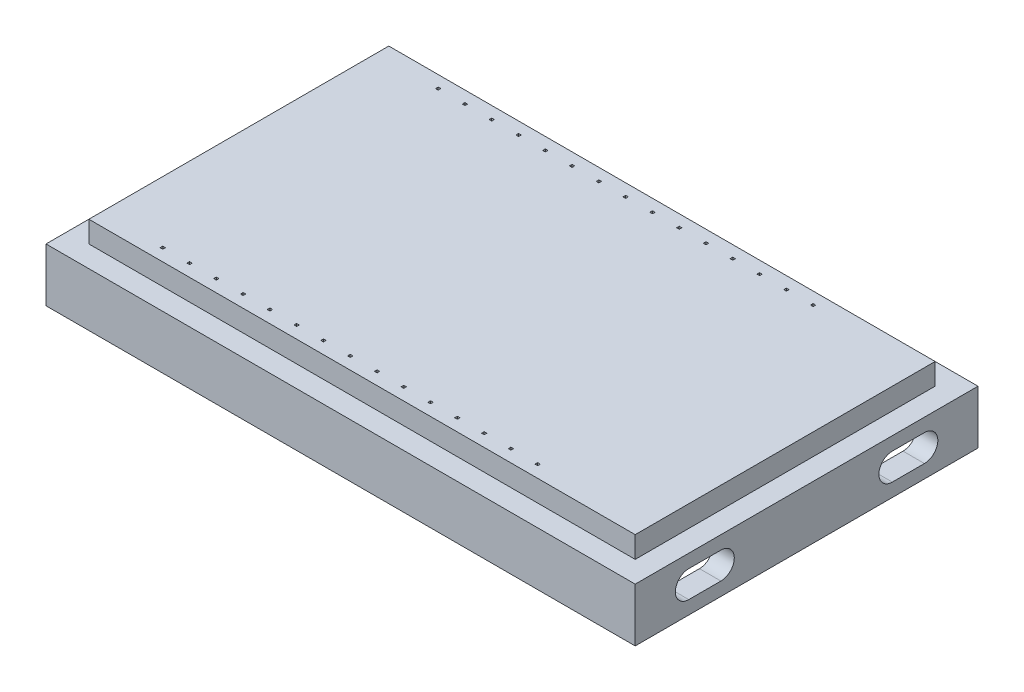
from build123d import *

# Parameters (mm, degrees)
CROQUIS1_W              = 51
CROQUIS1_H              = 28
CROQUIS1_W_2            = 0.25
CROQUIS1_H_2            = 0.25
SALIENTE_EXTRUIR1_DEPTH = 2
CROQUIS1_3_W            = 55
CROQUIS1_3_H            = 32
SALIENTE_EXTRUIR2_DEPTH = 5
CORTAR_EXTRUIR1_DEPTH   = 70
CORTAR_EXTRUIR2_DEPTH   = 5


with BuildPart() as part:
    # Croquis1 → Saliente-Extruir1 (new body)
    with BuildSketch(Plane(origin=(0, 0, 0), x_dir=(1, 0, 0), z_dir=(0, 1, 0))):
        Rectangle(CROQUIS1_W, CROQUIS1_H)
        with Locations((-19.75, -12.85)):
            Rectangle(CROQUIS1_W_2, CROQUIS1_H_2, mode=Mode.SUBTRACT)
        with Locations((-17.25, -12.85)):
            Rectangle(CROQUIS1_W_2, CROQUIS1_H_2, mode=Mode.SUBTRACT)
        with Locations((-14.75, -12.85)):
            Rectangle(CROQUIS1_W_2, CROQUIS1_H_2, mode=Mode.SUBTRACT)
        with Locations((-12.25, -12.85)):
            Rectangle(CROQUIS1_W_2, CROQUIS1_H_2, mode=Mode.SUBTRACT)
        with Locations((-9.75, -12.85)):
            Rectangle(CROQUIS1_W_2, CROQUIS1_H_2, mode=Mode.SUBTRACT)
        with Locations((-7.25, -12.85)):
            Rectangle(CROQUIS1_W_2, CROQUIS1_H_2, mode=Mode.SUBTRACT)
        with Locations((-4.75, -12.85)):
            Rectangle(CROQUIS1_W_2, CROQUIS1_H_2, mode=Mode.SUBTRACT)
        with Locations((-2.25, -12.85)):
            Rectangle(CROQUIS1_W_2, CROQUIS1_H_2, mode=Mode.SUBTRACT)
        with Locations((0.25, -12.85)):
            Rectangle(CROQUIS1_W_2, CROQUIS1_H_2, mode=Mode.SUBTRACT)
        with Locations((2.75, -12.85)):
            Rectangle(CROQUIS1_W_2, CROQUIS1_H_2, mode=Mode.SUBTRACT)
        with Locations((5.25, -12.85)):
            Rectangle(CROQUIS1_W_2, CROQUIS1_H_2, mode=Mode.SUBTRACT)
        with Locations((7.75, -12.85)):
            Rectangle(CROQUIS1_W_2, CROQUIS1_H_2, mode=Mode.SUBTRACT)
        with Locations((10.25, -12.85)):
            Rectangle(CROQUIS1_W_2, CROQUIS1_H_2, mode=Mode.SUBTRACT)
        with Locations((12.75, -12.85)):
            Rectangle(CROQUIS1_W_2, CROQUIS1_H_2, mode=Mode.SUBTRACT)
        with Locations((15.25, -12.85)):
            Rectangle(CROQUIS1_W_2, CROQUIS1_H_2, mode=Mode.SUBTRACT)
        with Locations((15.246139204, 12.863350571)):
            Rectangle(CROQUIS1_W_2, CROQUIS1_H_2, mode=Mode.SUBTRACT)
        with Locations((-19.753860796, 12.863350571)):
            Rectangle(CROQUIS1_W_2, CROQUIS1_H_2, mode=Mode.SUBTRACT)
        with Locations((-17.253860796, 12.863350571)):
            Rectangle(CROQUIS1_W_2, CROQUIS1_H_2, mode=Mode.SUBTRACT)
        with Locations((-14.753860796, 12.863350571)):
            Rectangle(CROQUIS1_W_2, CROQUIS1_H_2, mode=Mode.SUBTRACT)
        with Locations((-12.253860796, 12.863350571)):
            Rectangle(CROQUIS1_W_2, CROQUIS1_H_2, mode=Mode.SUBTRACT)
        with Locations((-9.753860796, 12.863350571)):
            Rectangle(CROQUIS1_W_2, CROQUIS1_H_2, mode=Mode.SUBTRACT)
        with Locations((-7.253860796, 12.863350571)):
            Rectangle(CROQUIS1_W_2, CROQUIS1_H_2, mode=Mode.SUBTRACT)
        with Locations((-4.753860796, 12.863350571)):
            Rectangle(CROQUIS1_W_2, CROQUIS1_H_2, mode=Mode.SUBTRACT)
        with Locations((-2.253860796, 12.863350571)):
            Rectangle(CROQUIS1_W_2, CROQUIS1_H_2, mode=Mode.SUBTRACT)
        with Locations((0.246139204, 12.863350571)):
            Rectangle(CROQUIS1_W_2, CROQUIS1_H_2, mode=Mode.SUBTRACT)
        with Locations((2.746139204, 12.863350571)):
            Rectangle(CROQUIS1_W_2, CROQUIS1_H_2, mode=Mode.SUBTRACT)
        with Locations((5.246139204, 12.863350571)):
            Rectangle(CROQUIS1_W_2, CROQUIS1_H_2, mode=Mode.SUBTRACT)
        with Locations((7.746139204, 12.863350571)):
            Rectangle(CROQUIS1_W_2, CROQUIS1_H_2, mode=Mode.SUBTRACT)
        with Locations((10.246139204, 12.863350571)):
            Rectangle(CROQUIS1_W_2, CROQUIS1_H_2, mode=Mode.SUBTRACT)
        with Locations((12.746139204, 12.863350571)):
            Rectangle(CROQUIS1_W_2, CROQUIS1_H_2, mode=Mode.SUBTRACT)
    extrude(amount=SALIENTE_EXTRUIR1_DEPTH)


with BuildPart() as body_2:
    # Croquis1_3 → Saliente-Extruir2 (new body)
    with BuildSketch(Plane(origin=(0, 0, 0), x_dir=(1, 0, 0), z_dir=(0, 1, 0))):
        Rectangle(CROQUIS1_3_W, CROQUIS1_3_H)
        Polygon((25.5, 14), (25.5, -14), (16.5, -14), (-21, -14), (-25.5, -14), (-25.5, 14), (-21, 14), (16.5, 14), align=None, mode=Mode.SUBTRACT)
    extrude(amount=-SALIENTE_EXTRUIR2_DEPTH)

    # Croquis2 → Cortar-Extruir1 (cut)
    with BuildSketch(Plane.ZY.offset(27.5)):
        with BuildLine():
            Line((8, -1.25), (11, -1.25))
            ThreePointArc((11, -1.25), (12.25, -2.5), (11, -3.75))
            Line((11, -3.75), (8, -3.75))
            ThreePointArc((8, -3.75), (6.75, -2.5), (8, -1.25))
        make_face()
    extrude(amount=-CORTAR_EXTRUIR1_DEPTH, mode=Mode.SUBTRACT)

    # Croquis3 → Cortar-Extruir2 (cut)
    with BuildSketch(Plane(origin=(27.5, 0, 0), x_dir=(0, 0, -1), z_dir=(1, 0, 0))):
        with BuildLine():
            Line((8, -1.25), (11, -1.25))
            ThreePointArc((11, -1.25), (12.25, -2.5), (11, -3.75))
            Line((11, -3.75), (8, -3.75))
            ThreePointArc((8, -3.75), (6.75, -2.5), (8, -1.25))
        make_face()
    extrude(amount=-CORTAR_EXTRUIR2_DEPTH, mode=Mode.SUBTRACT)


solid = Compound([part.part, body_2.part])
